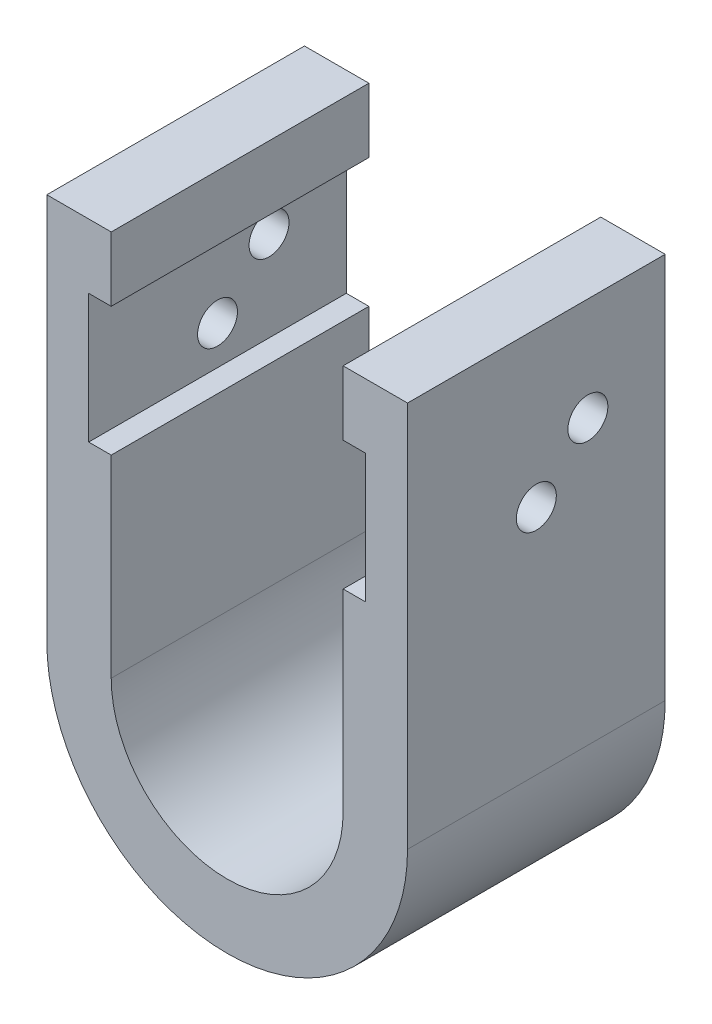
from build123d import *

# Parameters (mm, degrees)
EXTRUDE_1_DEPTH     = 20
SKETCH_2_R          = 1.55
CUT_EXTRUDE_1_DEPTH = 30
SKETCH_3_W          = 1.75
SKETCH_3_H          = 10
CUT_EXTRUDE_2_DEPTH = 20


with BuildPart() as part:
    # 草图1 → 凸台-拉伸1 (new body)
    with BuildSketch(Plane.XY):
        with BuildLine():
            Line((-14, 0), (-14, 30))
            Line((-14, 30), (-9, 30))
            Line((-9, 30), (-9, 0))
            ThreePointArc((-9, 0), (0, -9), (9, 0))
            Line((9, 0), (9, 30))
            Line((9, 30), (14, 30))
            Line((14, 30), (14, 0))
            ThreePointArc((14, 0), (0, -14), (-14, 0))
        make_face()
    extrude(amount=EXTRUDE_1_DEPTH)

    # 草图2 → 切除-拉伸1 (cut)
    with BuildSketch(Plane(origin=(14, 0, 0), x_dir=(0, 0, -1), z_dir=(1, 0, 0))):
        with Locations((-10, 18)):
            Circle(SKETCH_2_R)
        with Locations((-6, 22)):
            Circle(SKETCH_2_R)
    extrude(amount=-CUT_EXTRUDE_1_DEPTH, mode=Mode.SUBTRACT)

    # 草图3 → 切除-拉伸2 (cut)
    with BuildSketch(Plane(origin=(0, 0, 0), x_dir=(-1, 0, 0), z_dir=(0, 0, -1))):
        with Locations((-9.875, 20)):
            Rectangle(SKETCH_3_W, SKETCH_3_H)
    cut_extrude_2 = extrude(amount=-CUT_EXTRUDE_2_DEPTH, mode=Mode.SUBTRACT)

    # 镜向1: 切除-拉伸2 across plane
    add(cut_extrude_2.mirror(Plane(origin=(0, 0, 0), x_dir=(0, 0, 1), z_dir=(1, 0, 0))), mode=Mode.SUBTRACT)


solid = part.part
